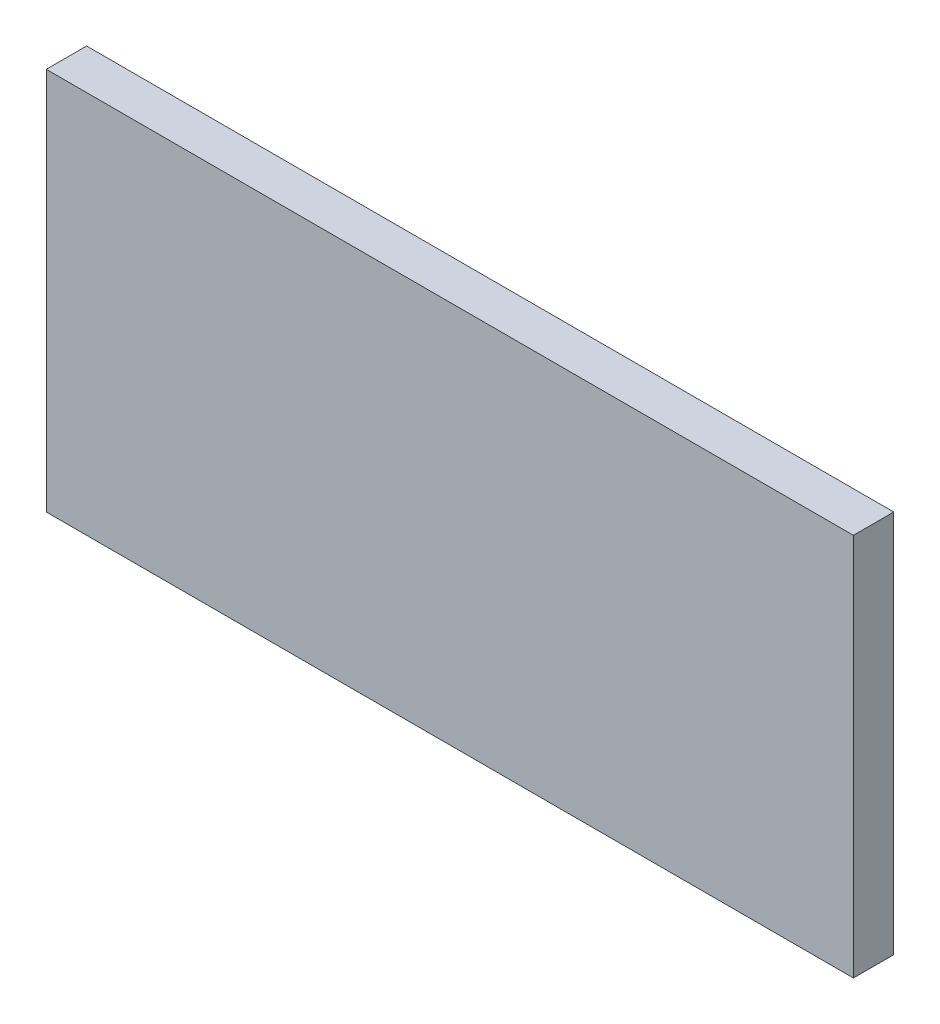
from build123d import *

# Parameters (mm, degrees)
SKETCH_1_W      = 40
SKETCH_1_H      = 19
EXTRUDE_1_DEPTH = 2


with BuildPart() as part:
    # 草图1 → 凸台-拉伸1 (new body)
    with BuildSketch(Plane.XY):
        with Locations((20, 9.5)):
            Rectangle(SKETCH_1_W, SKETCH_1_H)
    extrude(amount=EXTRUDE_1_DEPTH)


solid = part.part
